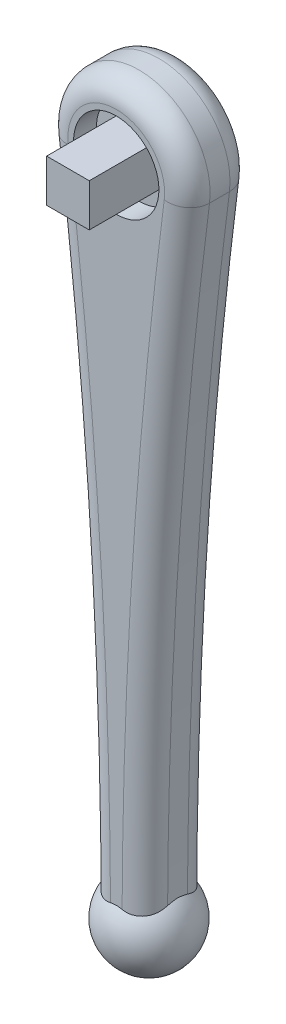
from build123d import *

# Parameters (mm, degrees)
SKETCH3_R               = 25
SKETCH3_R_2             = 15
BOSS_EXTRUDE1_DEPTH     = 8
SKETCH4_R               = 25
BOSS_EXTRUDE2_DEPTH     = 15
SKETCH5_W               = 15
SKETCH5_H               = 15
BOSS_EXTRUDE3_DEPTH     = 25
SKETCH6_R               = 10
BOSS_EXTRUDE4_DEPTH     = 23
FILLET1_R               = 8
FILLET2_R               = 8
SKETCH8_R               = 1.5
CUT_EXTRUDE1_DEPTH      = 26
CUT_EXTRUDE1_DEPTH_BACK = 19.5
SKETCH9_R               = 3.5
SKETCH9_R_2             = 1.5
CUT_EXTRUDE2_DEPTH      = 9


with BuildPart() as part:
    # Sketch3 → Boss-Extrude1 (new body)
    with BuildSketch(Plane.XY):
        Circle(SKETCH3_R)
        Circle(SKETCH3_R_2, mode=Mode.SUBTRACT)
    extrude(amount=BOSS_EXTRUDE1_DEPTH)

    # Sketch4 → Boss-Extrude2 (add)
    with BuildSketch(Plane(origin=(0, 0, 0), x_dir=(-1, 0, 0), z_dir=(0, 0, -1))):
        Circle(SKETCH4_R)
    extrude(amount=BOSS_EXTRUDE2_DEPTH)

    # Sketch5 → Boss-Extrude3 (add)
    with BuildSketch(Plane.XY):
        Rectangle(SKETCH5_W, SKETCH5_H)
    extrude(amount=BOSS_EXTRUDE3_DEPTH)

    # Sketch6 → Boss-Extrude4 (add)
    with BuildSketch(Plane(origin=(0, 0, -15), x_dir=(-1, 0, 0), z_dir=(0, 0, -1))):
        with BuildLine():
            ThreePointArc((-10, -235), (0, -225), (10, -235))
            ThreePointArc((10, -235), (13.703038867, -118.853386163), (24.797114339, -3.178540617))
            ThreePointArc((24.797114339, -3.178540617), (-9.25e-07, -25), (-24.797114574, -3.178538781))
            ThreePointArc((-24.797114574, -3.178538781), (-13.703038926, -118.853385239), (-10, -235))
        make_face()
        with Locations((0, -235)):
            Circle(SKETCH6_R)
    extrude(amount=-BOSS_EXTRUDE4_DEPTH)

    # Fillet1
    fillet1_edges = [part.edges().sort_by_distance(p)[0] for p in [
        (-9.25e-07, 25, -15),
        (0, -245, -15),
        (-13.703038867, -118.853386163, -15),
        (13.703038926, -118.853385239, -15),
    ]]
    fillet(fillet1_edges, radius=FILLET1_R)

    # Fillet2
    fillet2_edges = [part.edges().sort_by_distance(p)[0] for p in [
        (-9.25e-07, 25, 8),
        (13.703038926, -118.853385239, 8),
        (0, -245, 8),
        (-13.703038867, -118.853386163, 8),
    ]]
    fillet(fillet2_edges, radius=FILLET2_R)

    # Sketch8 → Cut-Extrude1 (cut, two sides)
    with BuildSketch(Plane.XY) as cut_extrude1_sk:
        with Locations((11.25, 0)):
            Circle(SKETCH8_R)
        with Locations((0, -11.25)):
            Circle(SKETCH8_R)
        with Locations((-11.25, 0)):
            Circle(SKETCH8_R)
        with Locations((0, 11.25)):
            Circle(SKETCH8_R)
    extrude(amount=CUT_EXTRUDE1_DEPTH, mode=Mode.SUBTRACT)
    extrude(cut_extrude1_sk.sketch, amount=-CUT_EXTRUDE1_DEPTH_BACK, mode=Mode.SUBTRACT)

    # Sketch9 → Cut-Extrude2 (cut)
    with BuildSketch(Plane(origin=(0, 0, -15), x_dir=(-1, 0, 0), z_dir=(0, 0, -1))):
        with Locations((11.25, 0)):
            Circle(SKETCH9_R)
        with Locations((11.25, 0)):
            Circle(SKETCH9_R_2, mode=Mode.SUBTRACT)
        with Locations((0, -11.25)):
            Circle(SKETCH9_R)
        with Locations((0, -11.25)):
            Circle(SKETCH9_R_2, mode=Mode.SUBTRACT)
        with Locations((-11.25, 0)):
            Circle(SKETCH9_R)
        with Locations((-11.25, 0)):
            Circle(SKETCH9_R_2, mode=Mode.SUBTRACT)
        with Locations((0, 11.25)):
            Circle(SKETCH9_R)
    extrude(amount=-CUT_EXTRUDE2_DEPTH, mode=Mode.SUBTRACT)


with BuildPart() as body_2:
    # Sketch7 one side → Revolve2 (revolve)
    with BuildSketch(Plane(origin=(0, 0, -3.5), x_dir=(-1, 0, 0), z_dir=(0, 0, -1))):
        with BuildLine():
            ThreePointArc((0, -250), (10.606601718, -245.606601718), (15, -235))
            ThreePointArc((15, -235), (10.606601718, -224.393398282), (0, -220))
            Line((0, -220), (0, -250))
        make_face()
    revolve(axis=Axis((0, -220, -3.5), (0, -1, 0)))


solid = Compound([part.part, body_2.part])
